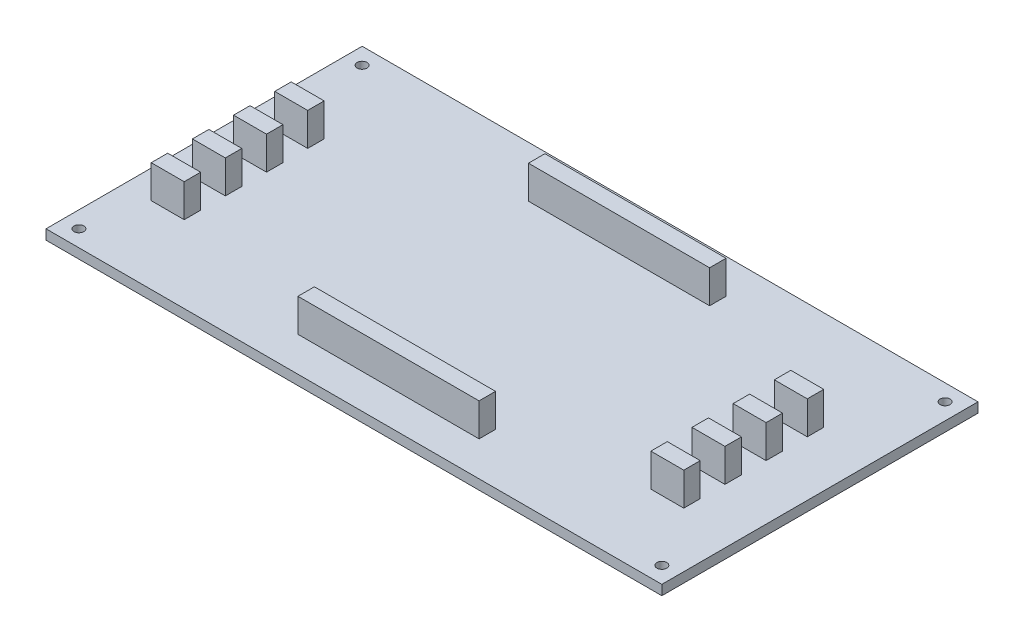
from build123d import *

# Parameters (mm, degrees)
ESQUISSE1_W      = 187
ESQUISSE1_H      = 96
ESQUISSE1_R      = 1.5
EXTRUSION1_DEPTH = 3
ESQUISSE2_W      = 55
ESQUISSE2_H      = 5
EXTRUSION2_DEPTH = 10
ESQUISSE4_W      = 10
ESQUISSE4_H      = 5
EXTRUSION4_DEPTH = 10


with BuildPart() as part:
    # Esquisse1 → Extrusion1 (new body)
    with BuildSketch(Plane(origin=(0, 0, 0), x_dir=(1, 0, 0), z_dir=(0, 1, 0))):
        with Locations((93.5, 48)):
            Rectangle(ESQUISSE1_W, ESQUISSE1_H)
        with Locations((5, 91)):
            Circle(ESQUISSE1_R, mode=Mode.SUBTRACT)
        with Locations((182, 91)):
            Circle(ESQUISSE1_R, mode=Mode.SUBTRACT)
        with Locations((182, 5)):
            Circle(ESQUISSE1_R, mode=Mode.SUBTRACT)
        with Locations((5, 5)):
            Circle(ESQUISSE1_R, mode=Mode.SUBTRACT)
    extrude(amount=EXTRUSION1_DEPTH)

    # Esquisse2 → Extrusion2 (add)
    with BuildSketch(Plane(origin=(0, 3, 0), x_dir=(1, 0, 0), z_dir=(0, 1, 0))):
        with Locations((93.5, 83)):
            Rectangle(ESQUISSE2_W, ESQUISSE2_H)
        with Locations((93.5, 13)):
            Rectangle(ESQUISSE2_W, ESQUISSE2_H)
    extrude(amount=EXTRUSION2_DEPTH)

    # Esquisse4 → Extrusion4 (add)
    with BuildSketch(Plane(origin=(0, 3, 0), x_dir=(1, 0, 0), z_dir=(0, 1, 0))):
        with Locations((165.295070297, 63.362289653)):
            Rectangle(ESQUISSE4_W, ESQUISSE4_H)
        with Locations((13.593769781, 63.362289653)):
            Rectangle(ESQUISSE4_W, ESQUISSE4_H)
        with Locations((13.593769781, 38.362289653)):
            Rectangle(ESQUISSE4_W, ESQUISSE4_H)
        with Locations((13.593769781, 25.862289653)):
            Rectangle(ESQUISSE4_W, ESQUISSE4_H)
        with Locations((13.593769781, 50.862289653)):
            Rectangle(ESQUISSE4_W, ESQUISSE4_H)
        with Locations((165.295070297, 38.362289653)):
            Rectangle(ESQUISSE4_W, ESQUISSE4_H)
        with Locations((165.295070297, 25.862289653)):
            Rectangle(ESQUISSE4_W, ESQUISSE4_H)
        with Locations((165.295070297, 50.862289653)):
            Rectangle(ESQUISSE4_W, ESQUISSE4_H)
    extrude(amount=EXTRUSION4_DEPTH)


solid = part.part
